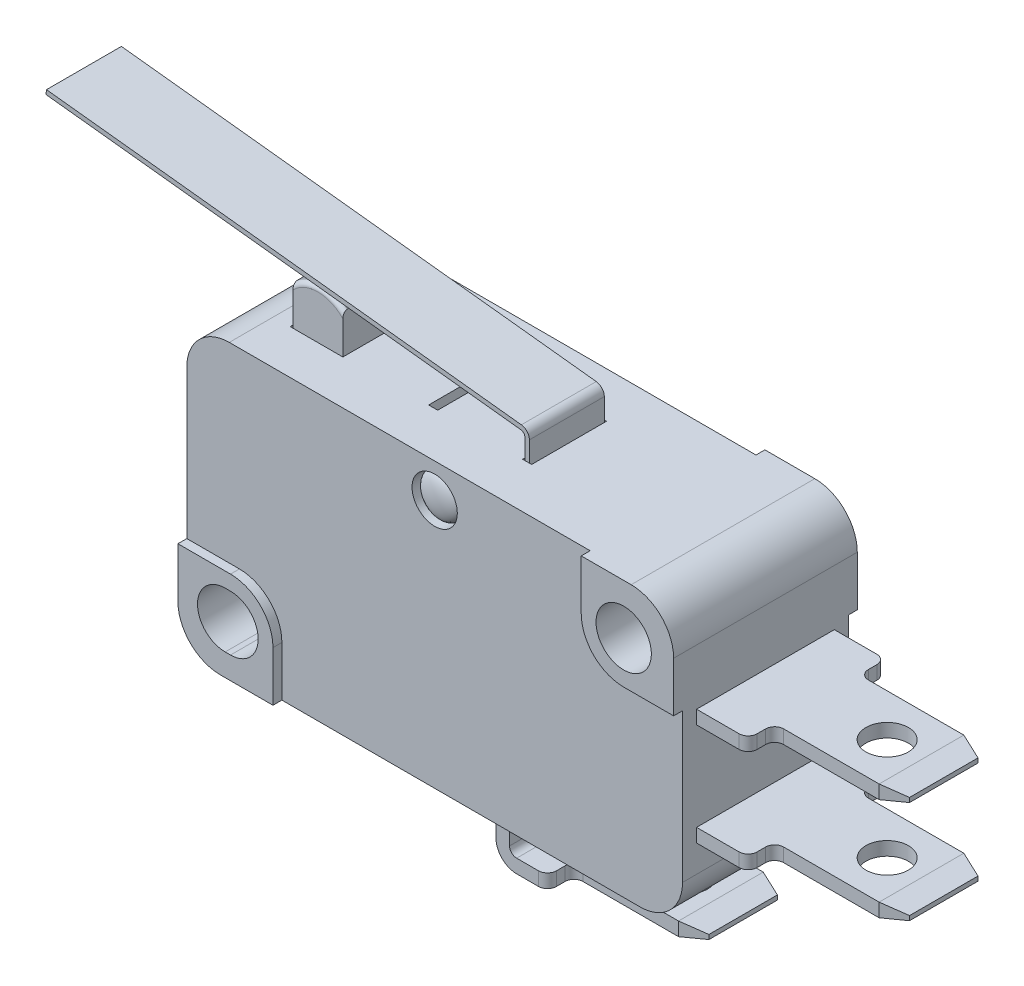
from build123d import *

# Parameters (mm, degrees)
SKETCH3_R                       = 1.55
BOSS_EXTRUDE1_DEPTH             = 5.15
BOSS_EXTRUDE1_DEPTH_BACK        = 5.15
CUT_EXTRUDE1_START              = 5.15
CUT_EXTRUDE1_DEPTH              = 0.5
SKETCH10_W                      = 0.508
SKETCH10_H                      = 1.5875
CUT_EXTRUDE5_DEPTH              = 2.1
CUT_EXTRUDE5_DEPTH_BACK         = 2.1
SKETCH8_W                       = 2.9524
SKETCH8_H                       = 0.396875
CUT_EXTRUDE4_DEPTH              = 2.1762
BOSS_EXTRUDE3_DEPTH             = 2.1
BOSS_EXTRUDE3_DEPTH_BACK        = 2.1
BOSS_EXTRUDE2_DEPTH             = 3.8625
BOSS_EXTRUDE2_2_DEPTH           = 3.8625
BOSS_EXTRUDE2_3_DEPTH           = 3.8625
BOSS_EXTRUDE9_REACH             = 28.644
BOSS_EXTRUDE9_DIRECTION_2_REACH = 28.644
FILLET5_R                       = 0.254
SKETCH6_OUTSIDE_W               = 61.146
SKETCH6_OUTSIDE_H               = 23.198
SKETCH6_OUTSIDE_R               = 1.190625
CUT_EXTRUDE2_DEPTH              = 28.871691861
CUT_EXTRUDE2_DEPTH_BACK         = 28.871691861
SKETCH7_OUTSIDE_W               = 61.146
SKETCH7_OUTSIDE_H               = 23.198
SKETCH7_OUTSIDE_R               = 1.190625
CUT_EXTRUDE3_DEPTH              = 28.871691861
SKETCH25_R                      = 1.27
CUT_EXTRUDE6_DEPTH              = 1.27
SKETCH26_R                      = 1.2065
BOSS_EXTRUDE10_DEPTH            = 0.762
DOME1_FACE_RADIUS               = 1.2065
DOME1_HEIGHT                    = 0.508


with BuildPart() as part:
    # Sketch3 → Boss-Extrude1 (new, two sides)
    with BuildSketch(Plane.XY) as boss_extrude1_sk:
        with BuildLine():
            Line((-11.51875, 7.95), (11.51875, 7.95))
            ThreePointArc((11.51875, 7.95), (13.202548023, 7.252548023), (13.9, 5.56875))
            Line((13.9, 5.56875), (13.9, -5.56875))
            ThreePointArc((13.9, -5.56875), (13.202548023, -7.252548023), (11.51875, -7.95))
            Line((11.51875, -7.95), (-11.51875, -7.95))
            ThreePointArc((-11.51875, -7.95), (-13.202548023, -7.252548023), (-13.9, -5.56875))
            Line((-13.9, -5.56875), (-13.9, 5.56875))
            ThreePointArc((-13.9, 5.56875), (-13.202548023, 7.252548023), (-11.51875, 7.95))
        make_face()
        with Locations(Location((11.1, 5.15, 0), (0, 0, 180))):
            Circle(SKETCH3_R, mode=Mode.SUBTRACT)
        with BuildLine():
            Line((-11.25, -3.6), (-10.95, -3.6))
            ThreePointArc((-10.95, -3.6), (-9.4, -5.15), (-10.95, -6.7))
            Line((-10.95, -6.7), (-11.25, -6.7))
            ThreePointArc((-11.25, -6.7), (-12.8, -5.15), (-11.25, -3.6))
        make_face(mode=Mode.SUBTRACT)
    extrude(amount=BOSS_EXTRUDE1_DEPTH)
    extrude(boss_extrude1_sk.sketch, amount=-BOSS_EXTRUDE1_DEPTH_BACK)

    # Sketch4 → Cut-Extrude1 (cut)
    with BuildSketch(Plane.XY.offset(CUT_EXTRUDE1_START)):
        with BuildLine():
            Line((-13.9, -2.76875), (-10.95, -2.76875))
            ThreePointArc((-10.95, -2.76875), (-9.266201977, -3.466201977), (-8.56875, -5.15))
            Line((-8.56875, -5.15), (-8.56875, -7.95))
            Line((-8.56875, -7.95), (13.9, -7.95))
            Line((13.9, -7.95), (13.9, 2.76875))
            Line((13.9, 2.76875), (11.1, 2.76875))
            ThreePointArc((11.1, 2.76875), (9.416201977, 3.466201977), (8.71875, 5.15))
            Line((8.71875, 5.15), (8.71875, 7.95))
            Line((8.71875, 7.95), (-13.9, 7.95))
            Line((-13.9, 7.95), (-13.9, -2.76875))
        make_face()
    cut_extrude1 = extrude(amount=-CUT_EXTRUDE1_DEPTH, mode=Mode.SUBTRACT)

    # Mirror1: Cut-Extrude1 across plane
    add(cut_extrude1.mirror(Plane.XY), mode=Mode.SUBTRACT)

    # Sketch10 → Cut-Extrude5 (cut, two sides)
    with BuildSketch(Plane.XY) as cut_extrude5_sk:
        with Locations((-2.63525, 7.15625)):
            Rectangle(SKETCH10_W, SKETCH10_H)
        with Locations((2.63525, 7.15625)):
            Rectangle(SKETCH10_W, SKETCH10_H)
    extrude(amount=CUT_EXTRUDE5_DEPTH, mode=Mode.SUBTRACT)
    extrude(cut_extrude5_sk.sketch, amount=-CUT_EXTRUDE5_DEPTH_BACK, mode=Mode.SUBTRACT)

    # Sketch8 → Cut-Extrude4 (cut, symmetric)
    with BuildSketch(Plane.XY):
        with Locations((-9.1, 7.7515625)):
            Rectangle(SKETCH8_W, SKETCH8_H)
    extrude(amount=CUT_EXTRUDE4_DEPTH, both=True, mode=Mode.SUBTRACT)

    # Sketch25 → Cut-Extrude6 (cut)
    with BuildSketch(Plane.XY.offset(4.65)):
        with Locations((0, 6.045)):
            Circle(SKETCH25_R)
    cut_extrude6 = extrude(amount=-CUT_EXTRUDE6_DEPTH, mode=Mode.SUBTRACT)

    # Mirror2: Cut-Extrude6 across plane
    add(cut_extrude6.mirror(Plane.XY), mode=Mode.SUBTRACT)


with BuildPart() as body_2:
    # Sketch9 → Boss-Extrude3 (new, two sides)
    with BuildSketch(Plane.XY) as boss_extrude3_sk:
        with BuildLine():
            Line((-10.5, 10.079506749), (-10.5, 7.553125))
            Line((-10.5, 7.553125), (-7.7, 7.553125))
            Line((-7.7, 7.553125), (-7.7, 10.079506749))
            ThreePointArc((-7.7, 10.079506749), (-9.1, 10.587506749), (-10.5, 10.079506749))
        make_face()
    extrude(amount=BOSS_EXTRUDE3_DEPTH)
    extrude(boss_extrude3_sk.sketch, amount=-BOSS_EXTRUDE3_DEPTH_BACK)


with BuildPart() as body_3:
    # Sketch5 → Boss-Extrude2 (new, symmetric)
    with BuildSketch(Plane.XY):
        Polygon((13.9, 1.688), (13.9, 2.45), (22.65, 2.45), (23.9, 2.194), (23.9, 1.944), (22.65, 1.688), align=None)
    extrude(amount=BOSS_EXTRUDE2_DEPTH, both=True)


with BuildPart() as body_4:
    # Sketch5 → Boss-Extrude2 2 (new, symmetric)
    with BuildSketch(Plane.XY):
        Polygon((13.9, -3.288), (22.65, -3.288), (23.9, -3.544), (23.9, -3.794), (22.65, -4.05), (13.9, -4.05), align=None)
    extrude(amount=BOSS_EXTRUDE2_2_DEPTH, both=True)


with BuildPart() as body_5:
    # Sketch5 → Boss-Extrude2 3 (new, symmetric)
    with BuildSketch(Plane.XY):
        with BuildLine():
            Line((2.65, -7.95), (2.65, -9.433125))
            ThreePointArc((2.65, -9.433125), (2.989426629, -10.252573371), (3.808875, -10.592))
            Line((3.808875, -10.592), (11.4, -10.592))
            Line((11.4, -10.592), (12.65, -10.336))
            Line((12.65, -10.336), (12.65, -10.086))
            Line((12.65, -10.086), (11.4, -9.83))
            Line((11.4, -9.83), (3.808875, -9.83))
            ThreePointArc((3.808875, -9.83), (3.528241996, -9.713758004), (3.412, -9.433125))
            Line((3.412, -9.433125), (3.412, -7.95))
            Line((3.412, -7.95), (2.65, -7.95))
        make_face()
    extrude(amount=BOSS_EXTRUDE2_3_DEPTH, both=True)

    # Sketch7 outside → Cut-Extrude3 (cut, through all)
    with BuildSketch(Plane(origin=(0, 0, 0), x_dir=(1, 0, 0), z_dir=(0, 1, 0))):
        with Locations((-0.224, 0)):
            Rectangle(SKETCH7_OUTSIDE_W, SKETCH7_OUTSIDE_H)
        with BuildLine():
            Line((2.65, 3.8625), (2.65, -3.8625))
            Line((2.65, -3.8625), (5.03125, -3.8625))
            ThreePointArc((5.03125, -3.8625), (5.390460245, -3.713710245), (5.53925, -3.3545))
            Line((5.53925, -3.3545), (5.53925, -2.8829))
            ThreePointArc((5.53925, -2.8829), (5.688039755, -2.523689755), (6.04725, -2.3749))
            Line((6.04725, -2.3749), (11.4, -2.3749))
            Line((11.4, -2.3749), (12.65, -1.919937207))
            Line((12.65, -1.919937207), (12.65, 1.919937207))
            Line((12.65, 1.919937207), (11.4, 2.3749))
            Line((11.4, 2.3749), (6.04725, 2.3749))
            ThreePointArc((6.04725, 2.3749), (5.688039755, 2.523689755), (5.53925, 2.8829))
            Line((5.53925, 2.8829), (5.53925, 3.3545))
            ThreePointArc((5.53925, 3.3545), (5.390460245, 3.713710245), (5.03125, 3.8625))
            Line((5.03125, 3.8625), (2.65, 3.8625))
        make_face(mode=Mode.SUBTRACT)
        with Locations(Location((9.475, 0, 0), (0, 0, 270))):
            Circle(SKETCH7_OUTSIDE_R)
    extrude(amount=-CUT_EXTRUDE3_DEPTH, mode=Mode.SUBTRACT)


with BuildPart() as body_6:

    # Boss-Extrude9: up to this face of the body (flat: up to its plane)
    boss_extrude9_end = Plane(body_2.part.faces().sort_by_distance((-9.1, 8.993855519, 2.1))[0])
    # Sketch23 → Boss-Extrude9 (new, up to the picked face)
    with BuildSketch(Plane.XY, mode=Mode.PRIVATE) as boss_extrude9_sk1:
        with BuildLine():
            Line((2.282338846, 9.334484128), (-24.34761194, 12.297557894))
            Line((-24.34761194, 12.297557894), (-24.319523094, 12.55))
            Line((-24.319523094, 12.55), (2.310427692, 9.586926234))
            ThreePointArc((2.310427692, 9.586926234), (2.632801362, 9.420808707), (2.76225, 9.082042023))
            Line((2.76225, 9.082042023), (2.76225, 6.3625))
            Line((2.76225, 6.3625), (2.50825, 6.3625))
            Line((2.50825, 6.3625), (2.50825, 9.082042023))
            ThreePointArc((2.50825, 9.082042023), (2.443525681, 9.251425365), (2.282338846, 9.334484128))
        make_face()
    boss_extrude9_tool1 = split(extrude(boss_extrude9_sk1.sketch, amount=BOSS_EXTRUDE9_REACH, mode=Mode.PRIVATE), bisect_by=boss_extrude9_end, keep=Keep.BOTH, mode=Mode.PRIVATE)
    add(boss_extrude9_tool1.solids().sort_by(Axis((2.464247, 9.269969, 0), (0, 0, 1)))[0])


    # Boss-Extrude9 direction 2: up to this face of the body (flat: up to its plane)
    boss_extrude9_direction_2_end = Plane(body_2.part.faces().sort_by_distance((-9.1, 8.993855519, -2.1))[0])
    # Sketch23 → Boss-Extrude9 direction 2 (add, up to the picked face)
    with BuildSketch(Plane.XY, mode=Mode.PRIVATE) as boss_extrude9_direction_2_sk1:
        with BuildLine():
            Line((2.282338846, 9.334484128), (-24.34761194, 12.297557894))
            Line((-24.34761194, 12.297557894), (-24.319523094, 12.55))
            Line((-24.319523094, 12.55), (2.310427692, 9.586926234))
            ThreePointArc((2.310427692, 9.586926234), (2.632801362, 9.420808707), (2.76225, 9.082042023))
            Line((2.76225, 9.082042023), (2.76225, 6.3625))
            Line((2.76225, 6.3625), (2.50825, 6.3625))
            Line((2.50825, 6.3625), (2.50825, 9.082042023))
            ThreePointArc((2.50825, 9.082042023), (2.443525681, 9.251425365), (2.282338846, 9.334484128))
        make_face()
    boss_extrude9_direction_2_tool1 = split(extrude(boss_extrude9_direction_2_sk1.sketch, amount=-BOSS_EXTRUDE9_DIRECTION_2_REACH, mode=Mode.PRIVATE), bisect_by=boss_extrude9_direction_2_end, keep=Keep.BOTH, mode=Mode.PRIVATE)
    add(boss_extrude9_direction_2_tool1.solids().sort_by(Axis((2.464247, 9.269969, 0), (0, 0, -1)))[0])


with BuildPart() as body_2_1:
    add(body_2.part)

    # Fillet5
    fillet5_edges = [body_2_1.edges().sort_by_distance(p)[0] for p in [
        (-9.1, 10.587506749, -2.1),
        (-9.1, 10.587506749, 2.1),
    ]]
    fillet(fillet5_edges, radius=FILLET5_R)


with BuildPart() as cut_extrude2_tool:
    # Sketch6 outside → Cut-Extrude2 (new, two sides)
    with BuildSketch(Plane(origin=(0, 0, 0), x_dir=(1, 0, 0), z_dir=(0, 1, 0))) as cut_extrude2_sk:
        with Locations((-0.224, 0)):
            Rectangle(SKETCH6_OUTSIDE_W, SKETCH6_OUTSIDE_H)
        with BuildLine():
            Line((13.9, 3.8625), (13.9, -3.8625))
            Line((13.9, -3.8625), (16.28125, -3.8625))
            ThreePointArc((16.28125, -3.8625), (16.640460245, -3.713710245), (16.78925, -3.3545))
            Line((16.78925, -3.3545), (16.78925, -2.8829))
            ThreePointArc((16.78925, -2.8829), (16.938039755, -2.523689755), (17.29725, -2.3749))
            Line((17.29725, -2.3749), (22.65, -2.3749))
            Line((22.65, -2.3749), (23.9, -1.919937207))
            Line((23.9, -1.919937207), (23.9, 1.919937207))
            Line((23.9, 1.919937207), (22.65, 2.3749))
            Line((22.65, 2.3749), (17.29725, 2.3749))
            ThreePointArc((17.29725, 2.3749), (16.938039755, 2.523689755), (16.78925, 2.8829))
            Line((16.78925, 2.8829), (16.78925, 3.3545))
            ThreePointArc((16.78925, 3.3545), (16.640460245, 3.713710245), (16.28125, 3.8625))
            Line((16.28125, 3.8625), (13.9, 3.8625))
        make_face(mode=Mode.SUBTRACT)
        with Locations(Location((20.725, 0, 0), (0, 0, 270))):
            Circle(SKETCH6_OUTSIDE_R)
    extrude(amount=CUT_EXTRUDE2_DEPTH)
    extrude(cut_extrude2_sk.sketch, amount=-CUT_EXTRUDE2_DEPTH_BACK)


with BuildPart() as body_4_1:
    add(body_4.part)

    # Cut-Extrude2: cut by cut_extrude2_tool
    add(cut_extrude2_tool.part, mode=Mode.SUBTRACT)


with BuildPart() as body_3_1:
    add(body_3.part)

    # Cut-Extrude2: cut by cut_extrude2_tool
    add(cut_extrude2_tool.part, mode=Mode.SUBTRACT)


with BuildPart() as body_7:
    # Sketch26 → Boss-Extrude10 (new body)
    with BuildSketch(Plane.XY.offset(3.38)):
        with Locations(Location((0, 6.045, 0), (0, 0, 180))):
            Circle(SKETCH26_R)
    extrude(amount=BOSS_EXTRUDE10_DEPTH)

    # Dome1: an elliptical dome of height H over a round flat face of radius A is half a spheroid: the quarter ellipse of half axes A and H revolved about the face's axis
    with BuildSketch(Plane((0, 6.045, 4.142), x_dir=(0, 1, 0), z_dir=(1, 0, 0)), mode=Mode.PRIVATE) as dome1_quarter:
        Ellipse(DOME1_FACE_RADIUS, DOME1_HEIGHT)
        Rectangle(DOME1_FACE_RADIUS, DOME1_HEIGHT, align=(Align.MIN, Align.MIN), mode=Mode.INTERSECT)
    revolve(dome1_quarter.sketch, axis=Axis((0, 6.045, 4.142), (0, 0, 1)))


with BuildPart() as body_8:
    # Mirror3: mirrored copy
    add(body_7.part.mirror(Plane.XY))


solid = Compound([part.part, body_5.part, body_6.part, body_2_1.part, body_4_1.part, body_3_1.part, body_7.part, body_8.part])
